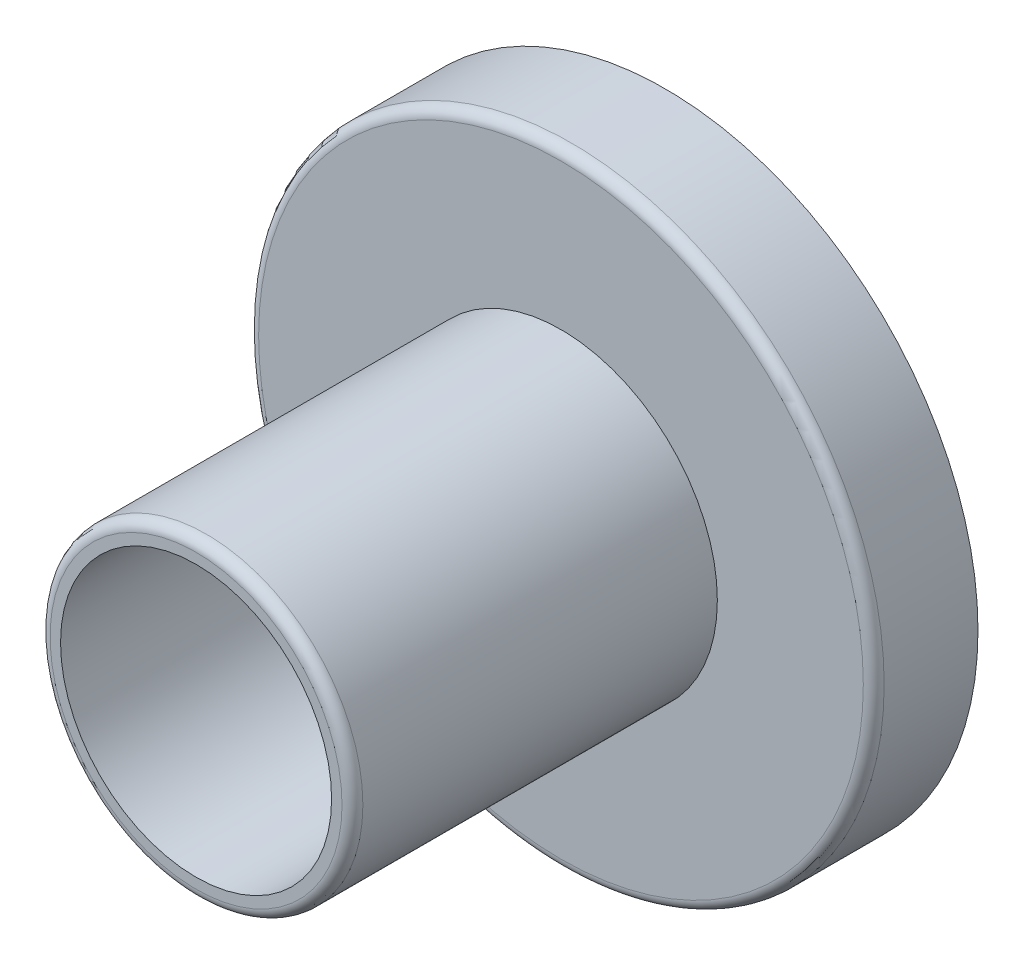
from build123d import *

# Parameters (mm, degrees)
CROQUIS1_R              = 30
SALIENTE_EXTRUIR1_DEPTH = 10
CROQUIS2_R              = 15
SALIENTE_EXTRUIR2_DEPTH = 35
VACIADO1_T              = -2
REDONDEO1_R             = 1
REDONDEO2_R             = 1
CORTAR_EXTRUIR1_REACH   = 62.407
CROQUIS3_R              = 5


with BuildPart() as part:
    # Croquis1 → Saliente-Extruir1 (new body)
    with BuildSketch(Plane.XY):
        Circle(CROQUIS1_R)
    extrude(amount=SALIENTE_EXTRUIR1_DEPTH)

    # Croquis2 → Saliente-Extruir2 (add)
    with BuildSketch(Plane.XY.offset(10)):
        Circle(CROQUIS2_R)
    extrude(amount=SALIENTE_EXTRUIR2_DEPTH)

    # Vaciado1
    vaciado1_openings = [part.faces().sort_by_distance(p)[0] for p in [
        (0, 0, 45),
    ]]
    offset(amount=VACIADO1_T, openings=vaciado1_openings, kind=Kind.INTERSECTION)

    # Redondeo1
    redondeo1_edges = [part.edges().sort_by_distance(p)[0] for p in [
        (-30, 0, 10),
    ]]
    fillet(redondeo1_edges, radius=REDONDEO1_R)

    # Redondeo2
    redondeo2_edges = [part.edges().sort_by_distance(p)[0] for p in [
        (-15, 0, 45),
    ]]
    fillet(redondeo2_edges, radius=REDONDEO2_R)

    # Croquis3 → Cortar-Extruir1 (cut, up to next)
    with BuildSketch(Plane.XY.offset(2), mode=Mode.PRIVATE) as cortar_extruir1_sk1:
        Circle(CROQUIS3_R)
    cortar_extruir1_tool1 = extrude(cortar_extruir1_sk1.sketch, amount=-CORTAR_EXTRUIR1_REACH, mode=Mode.PRIVATE) & part.part
    add(cortar_extruir1_tool1.solids().sort_by_distance((0, 0, 2))[0], mode=Mode.SUBTRACT)


solid = part.part
